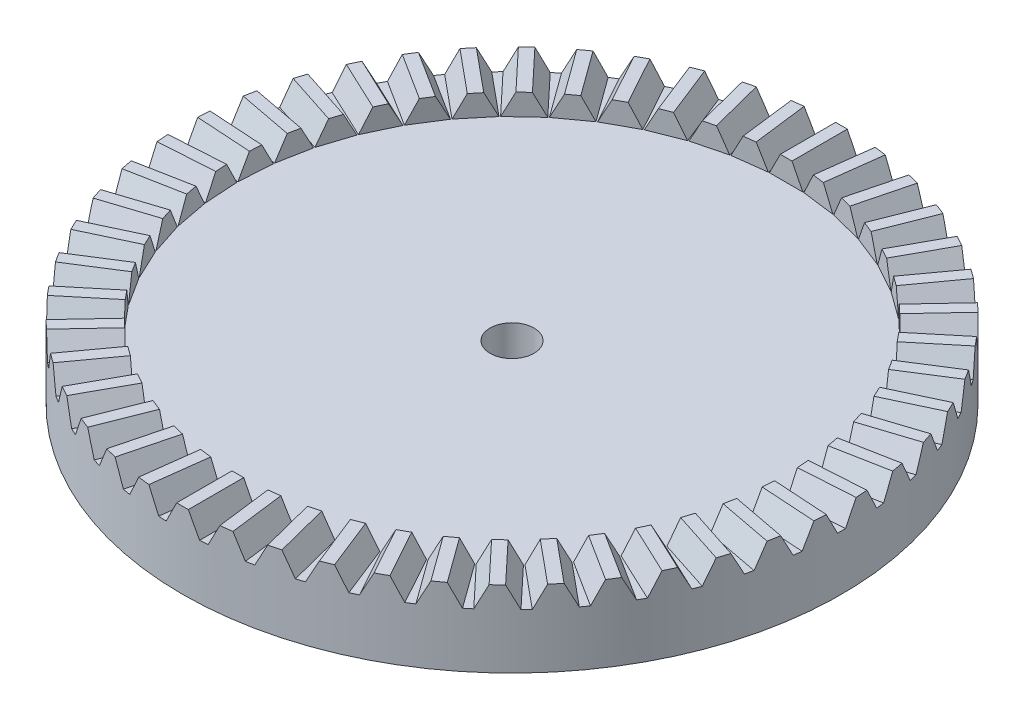
from build123d import *

# Parameters (mm, degrees)
SKETCH3_R           = 30
BOSS_EXTRUDE3_DEPTH = 5
CUT_EXTRUDE1_REACH  = 7
SKETCH6_R           = 2
BOSS_EXTRUDE5_DEPTH = 3
CUT_EXTRUDE4_DEPTH  = 5.041114
CIRPATTERN2_COUNT   = 50


with BuildPart() as part:
    # Sketch3 → Boss-Extrude3 (new body)
    with BuildSketch(Plane(origin=(0, 0, 0), x_dir=(1, 0, 0), z_dir=(0, 1, 0))):
        Circle(SKETCH3_R)
    extrude(amount=BOSS_EXTRUDE3_DEPTH)

    # Sketch6 → Cut-Extrude1 (cut, up to next)
    with BuildSketch(Plane(origin=(0, 5, 0), x_dir=(1, 0, 0), z_dir=(0, 1, 0)), mode=Mode.PRIVATE) as cut_extrude1_sk1:
        Circle(SKETCH6_R)
    cut_extrude1_tool1 = extrude(cut_extrude1_sk1.sketch, amount=-CUT_EXTRUDE1_REACH, mode=Mode.PRIVATE) & part.part
    add(cut_extrude1_tool1.solids().sort_by_distance((0, 5, 0))[0], mode=Mode.SUBTRACT)

    # Sketch5 → Boss-Extrude5 (add)
    with BuildSketch(Plane(origin=(0, 5, 0), x_dir=(1, 0, 0), z_dir=(0, 1, 0))):
        with BuildLine():
            Line((-1.570078687, 29.958886043), (-1.570078687, 24.958886043))
            Line((-1.570078687, 24.958886043), (1.570078687, 24.958886043))
            Line((1.570078687, 24.958886043), (1.570078687, 29.958886043))
            ThreePointArc((1.570078687, 29.958886043), (0, 30), (-1.570078687, 29.958886043))
        make_face()
    boss_extrude5 = extrude(amount=BOSS_EXTRUDE5_DEPTH)

    # Sketch14 → Cut-Extrude4 (cut)
    with BuildSketch(Plane.XY.offset(-24.958886043)):
        Polygon((0.532027541, 6.95), (-0.532027541, 6.95), (-1.520078687, 5), (-1.570078687, 5), (-1.570078687, 8), (1.570078687, 8), (1.570078687, 5), (1.520078687, 5), align=None)
    cut_extrude4 = extrude(amount=-CUT_EXTRUDE4_DEPTH, mode=Mode.SUBTRACT)

    # CirPattern2: Boss-Extrude5, Cut-Extrude4 ×50 about axis
    cirpattern2_axis = Axis((0, 0, 0), (0, 1, 0))
    for i in range(1, CIRPATTERN2_COUNT):
        add(boss_extrude5.rotate(cirpattern2_axis, i * 360 / CIRPATTERN2_COUNT))
        add(cut_extrude4.rotate(cirpattern2_axis, i * 360 / CIRPATTERN2_COUNT), mode=Mode.SUBTRACT)


solid = part.part
